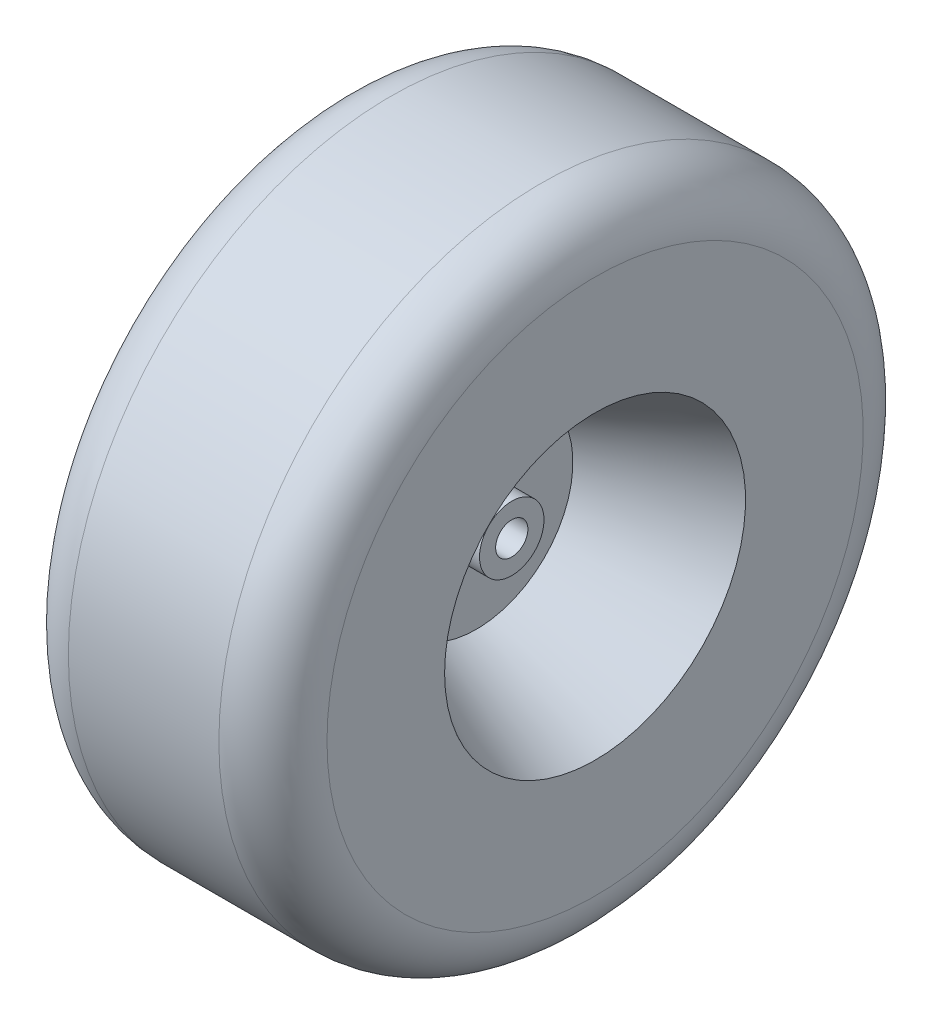
from build123d import *


with BuildPart() as part:
    # Sketch1 → Revolve1 (revolve)
    with BuildSketch(Plane.XY):
        with BuildLine():
            Line((-26.9875, 9.525), (26.9875, 9.525))
            Line((26.9875, 9.525), (26.9875, 19.05))
            Line((26.9875, 19.05), (6.112639692, 19.05))
            Line((6.112639692, 19.05), (6.112639692, 56.974587415))
            Line((6.112639692, 56.974587415), (76.2, 88.9))
            Line((76.2, 88.9), (76.2, 158.372961578))
            ThreePointArc((76.2, 158.372961578), (66.923900362, 180.957937381), (44.45, 190.5))
            Line((44.45, 190.5), (-44.45, 190.5))
            ThreePointArc((-44.45, 190.5), (-66.923900362, 180.957937381), (-76.2, 158.372961578))
            Line((-76.2, 158.372961578), (-76.2, 88.9))
            Line((-76.2, 88.9), (-6.112639692, 56.974587415))
            Line((-6.112639692, 56.974587415), (-6.112639692, 19.05))
            Line((-6.112639692, 19.05), (-26.9875, 19.05))
            Line((-26.9875, 19.05), (-26.9875, 9.525))
        make_face()
    revolve(axis=Axis((-76.2, 0, 0), (1, 0, 0)))


solid = part.part
